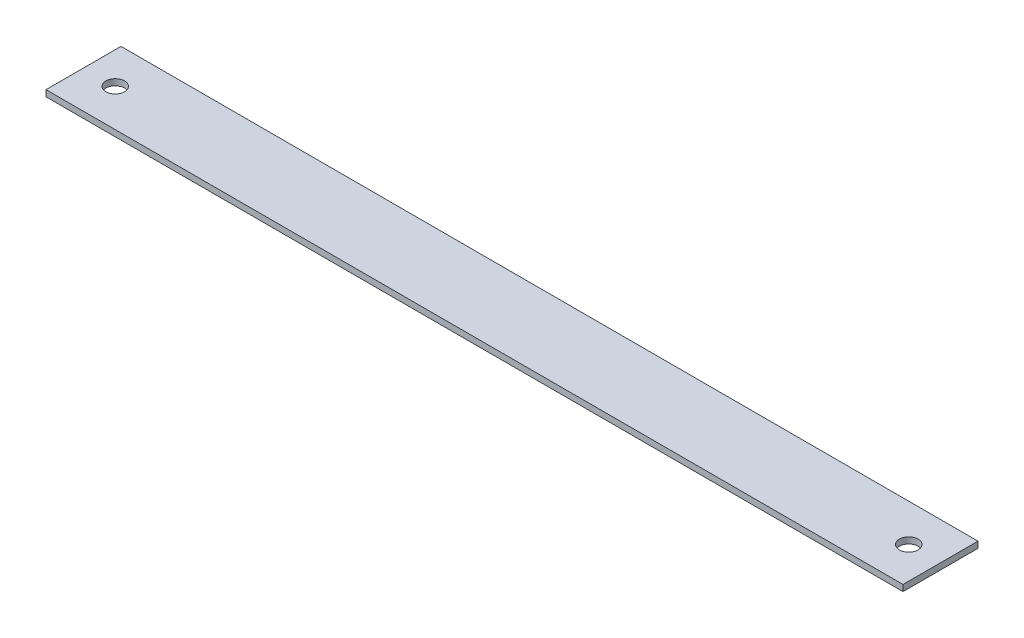
from build123d import *

# Parameters (mm, degrees)
SKETCH1_W           = 685.8
SKETCH1_H           = 60
SKETCH1_R           = 7.5
BOSS_EXTRUDE1_DEPTH = 5


with BuildPart() as part:
    # Sketch1 → Boss-Extrude1 (new body)
    with BuildSketch(Plane(origin=(0, 0, 0), x_dir=(1, 0, 0), z_dir=(0, 1, 0))):
        with Locations((342.9, 30)):
            Rectangle(SKETCH1_W, SKETCH1_H)
        with Locations((660.4, 30)):
            Circle(SKETCH1_R, mode=Mode.SUBTRACT)
        with Locations((25.4, 30)):
            Circle(SKETCH1_R, mode=Mode.SUBTRACT)
    extrude(amount=BOSS_EXTRUDE1_DEPTH)


solid = part.part
